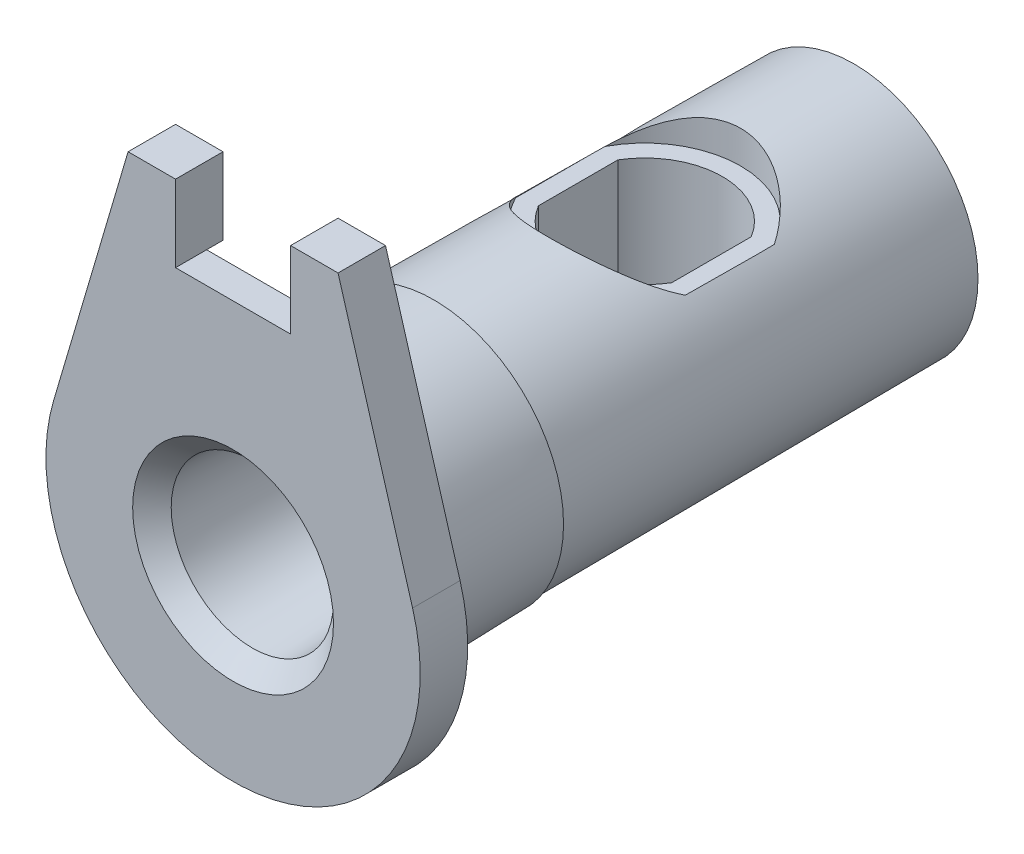
from build123d import *

# Parameters (mm, degrees)
BOSS_EXTRUDE1_DEPTH = 2.6
CUT_EXTRUDE1_DEPTH  = 0.9
SKETCH4_R           = 4.5
CUT_EXTRUDE2_DEPTH  = 16
CUT_EXTRUDE2_DRAFT  = -3
SKETCH5_R           = 3.1
CUT_EXTRUDE3_DEPTH  = 1.75
CUT_EXTRUDE4_DEPTH  = 43.200740515
CUT_EXTRUDE5_DEPTH  = 7.5
CHAMFER1_SIZE       = 1
CHAMFER1_SIZE2      = 1.056754503


with BuildPart() as part:
    # Sketch1 → Revolve1 (revolve)
    with BuildSketch(Plane(origin=(0, 0, 0), x_dir=(0, 0, -1), z_dir=(1, 0, 0)), mode=Mode.PRIVATE) as revolve1_sk:
        Polygon((34, 0), (34, 6.8), (11, 6.95), (11, 7.1), (0, 7.4), (0, 0), align=None)
    revolve(revolve1_sk.sketch.rotate(Axis((0, 0, 0), (0, 0, -1)), 90), axis=Axis((0, 0, 0), (0, 0, -1)))

    # Sketch2 → Boss-Extrude1 (add)
    with BuildSketch(Plane.XY):
        with BuildLine():
            Line((-9.832020922, 2.897216699), (-5.75, 16.75))
            Line((-5.75, 16.75), (-3.15, 16.75))
            Line((-3.15, 16.75), (-3.15, 12.55))
            Line((-3.15, 12.55), (3.15, 12.55))
            Line((3.15, 12.55), (3.15, 16.75))
            Line((3.15, 16.75), (5.75, 16.75))
            Line((5.75, 16.75), (9.832020922, 2.897216699))
            ThreePointArc((9.832020922, 2.897216699), (0, -10.25), (-9.832020922, 2.897216699))
        make_face()
    extrude(amount=-BOSS_EXTRUDE1_DEPTH)

    # Sketch3 → Cut-Extrude1 (cut)
    with BuildSketch(Plane(origin=(0, 0, -2.6), x_dir=(-1, 0, 0), z_dir=(0, 0, -1))):
        with BuildLine():
            Line((-5.821011016, 11.555986793), (-5.519758848, 6.917713659))
            ThreePointArc((-5.519758848, 6.917713659), (0, 8.85), (5.519758848, 6.917713659))
            Line((5.519758848, 6.917713659), (5.821011016, 11.555986793))
            ThreePointArc((5.821011016, 11.555986793), (0, 12.939281278), (-5.821011016, 11.555986793))
        make_face()
    extrude(amount=-CUT_EXTRUDE1_DEPTH, mode=Mode.SUBTRACT)


with BuildPart() as cut_extrude2_tool:
    # Sketch4 → Cut-Extrude2 (with draft: the straight prism first)
    with BuildSketch(Plane.XY):
        Circle(SKETCH4_R)
    extrude(amount=-CUT_EXTRUDE2_DEPTH)
    # Cut-Extrude2: the draft: its side faces are tilted about the plane it starts from
    cut_extrude2_sides = [cut_extrude2_tool.faces().sort_by_distance(p)[0] for p in [
        (-4.5, 0, -8),
    ]]
    draft(cut_extrude2_sides, Plane.XY, CUT_EXTRUDE2_DRAFT)


with BuildPart() as part_1:
    add(part.part)

    # Cut-Extrude2: cut by cut_extrude2_tool
    add(cut_extrude2_tool.part, mode=Mode.SUBTRACT)

    # Sketch5 → Cut-Extrude3 (cut)
    with BuildSketch(Plane(origin=(0, 0, -34), x_dir=(-1, 0, 0), z_dir=(0, 0, -1))):
        Circle(SKETCH5_R)
    extrude(amount=-CUT_EXTRUDE3_DEPTH, mode=Mode.SUBTRACT)

    # Sketch6 → Cut-Extrude4 (cut, through all)
    with BuildSketch(Plane(origin=(0, 12.55, 0), x_dir=(1, 0, 0), z_dir=(0, 1, 0))):
        with BuildLine():
            Line((-3.65, 20.372845894), (-3.65, 24.727154106))
            ThreePointArc((-3.65, 24.727154106), (0, 26.8), (3.65, 24.727154106))
            Line((3.65, 24.727154106), (3.65, 20.372845894))
            ThreePointArc((3.65, 20.372845894), (0, 18.3), (-3.65, 20.372845894))
        make_face()
    extrude(amount=-CUT_EXTRUDE4_DEPTH, mode=Mode.SUBTRACT)

    # Sketch7 → Cut-Extrude5 (cut)
    with BuildSketch(Plane(origin=(0, 12.55, 0), x_dir=(1, 0, 0), z_dir=(0, 1, 0))):
        with BuildLine():
            Line((4.65, 20.112788479), (4.65, 24.987211521))
            ThreePointArc((4.65, 24.987211521), (0, 27.8), (-4.65, 24.987211521))
            Line((-4.65, 24.987211521), (-4.65, 20.112788479))
            ThreePointArc((-4.65, 20.112788479), (0, 17.3), (4.65, 20.112788479))
        make_face()
    extrude(amount=-CUT_EXTRUDE5_DEPTH, mode=Mode.SUBTRACT)

    # Chamfer1
    chamfer1_edges = [part_1.edges().sort_by_distance(p)[0] for p in [
        (-4.5, 0, 0),
    ]]
    chamfer1_side = [part_1.faces().sort_by_distance(p)[0] for p in [
        (-7.465828695, 9.727786539, 0),
    ]]
    chamfer(chamfer1_edges, length=CHAMFER1_SIZE, length2=CHAMFER1_SIZE2, reference=chamfer1_side[0])


solid = part_1.part
